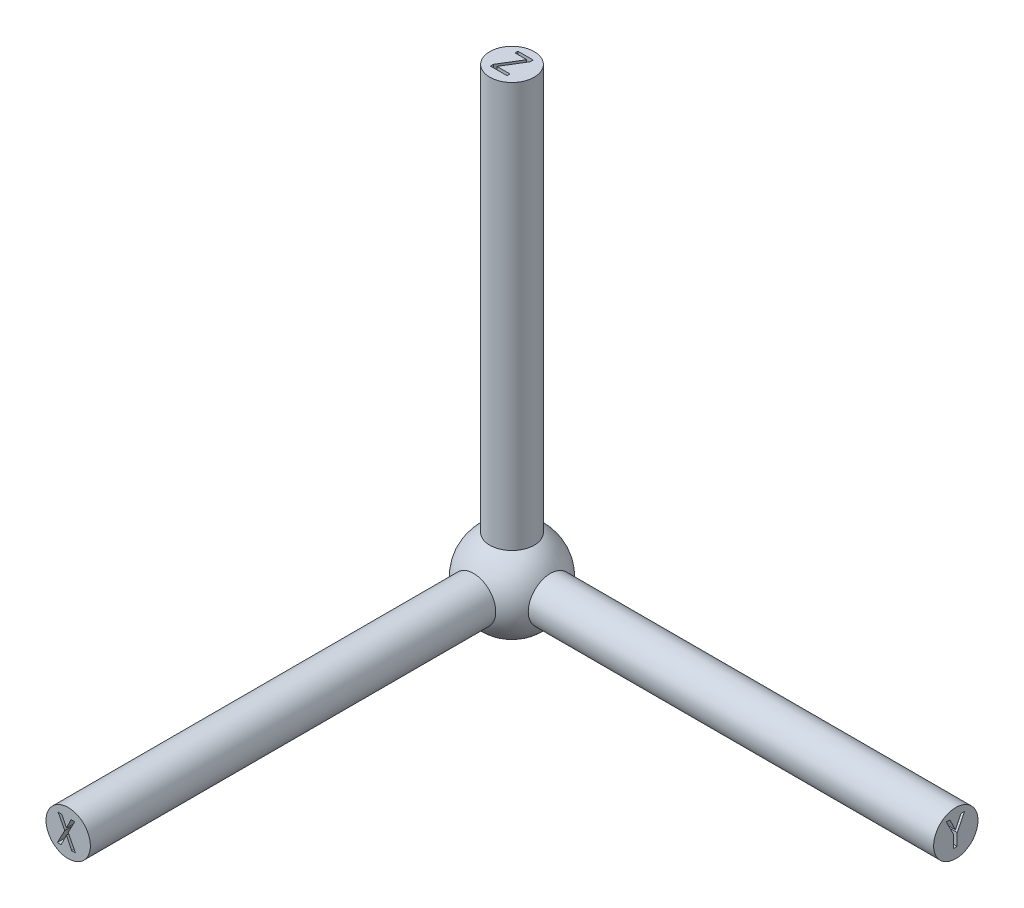
from build123d import *

# Parameters (mm, degrees)
SKETCH_2_R          = 0.5
EXTRUDE_1_DEPTH     = 10
SKETCH_3_R          = 0.5
EXTRUDE_2_DEPTH     = 10
SKETCH_4_R          = 0.5
EXTRUDE_3_DEPTH     = 10
CUT_EXTRUDE_1_DEPTH = 1
CUT_EXTRUDE_2_DEPTH = 1
CUT_EXTRUDE_3_DEPTH = 1


with BuildPart() as part:
    # 草图1 → 旋转1 (revolve)
    with BuildSketch(Plane.XY):
        with BuildLine():
            Line((0, 1), (0, -1))
            ThreePointArc((0, -1), (-1, 0), (0, 1))
        make_face()
    revolve(axis=Axis((0, 1, 0), (0, -1, 0)))

    # 草图2 → 凸台-拉伸1 (add)
    with BuildSketch(Plane(origin=(0, 0, 0), x_dir=(1, 0, 0), z_dir=(0, 1, 0))):
        Circle(SKETCH_2_R)
    extrude(amount=EXTRUDE_1_DEPTH)

    # 草图3 → 凸台-拉伸2 (add)
    with BuildSketch(Plane(origin=(0, 0, 0), x_dir=(0, 0, -1), z_dir=(1, 0, 0))):
        Circle(SKETCH_3_R)
    extrude(amount=EXTRUDE_2_DEPTH)

    # 草图4 → 凸台-拉伸3 (add)
    with BuildSketch(Plane.XY):
        Circle(SKETCH_4_R)
    extrude(amount=EXTRUDE_3_DEPTH)

    # 草图5 → 切除-拉伸1 (cut)
    with BuildSketch(Plane.XY.offset(10)):
        Polygon((0.164271664, -0.305303511), (0.080061137, -0.305303511), (-0.039237108, -0.059689476), (-0.158535354, -0.305303511), (-0.24274588, -0.305303511), (-0.0778336, 0.010485963), (-0.225202021, 0.294696489), (-0.140991494, 0.294696489), (-0.039237108, 0.07715263), (0.062517278, 0.294696489), (0.146727804, 0.294696489), (-0.000640617, 0.010485963), align=None)
    extrude(amount=-CUT_EXTRUDE_1_DEPTH, mode=Mode.SUBTRACT)

    # 草图6 → 切除-拉伸2 (cut)
    with BuildSketch(Plane(origin=(10, 0, 0), x_dir=(0, 0, -1), z_dir=(1, 0, 0))):
        Polygon((0.196855421, 0.324059335), (0.03194314, -0.005765227), (0.03194314, -0.275940665), (-0.048758614, -0.275940665), (-0.048758614, -0.005765227), (-0.213670895, 0.324059335), (-0.13296914, 0.324059335), (-0.010162123, 0.067918984), (-0.006653351, 0.067918984), (0.116153667, 0.324059335), align=None)
    extrude(amount=-CUT_EXTRUDE_2_DEPTH, mode=Mode.SUBTRACT)

    # 草图7 → 切除-拉伸3 (cut)
    with BuildSketch(Plane(origin=(0, 10, 0), x_dir=(1, 0, 0), z_dir=(0, 1, 0))):
        Polygon((0.164917999, -0.276228525), (-0.210520598, -0.276228525), (-0.210520598, -0.209561858), (0.073689928, 0.257104808), (-0.189467966, 0.257104808), (-0.189467966, 0.323771475), (0.154391683, 0.323771475), (0.154391683, 0.257104808), (-0.129818843, -0.209561858), (0.164917999, -0.209561858), align=None)
    extrude(amount=-CUT_EXTRUDE_3_DEPTH, mode=Mode.SUBTRACT)


solid = part.part
